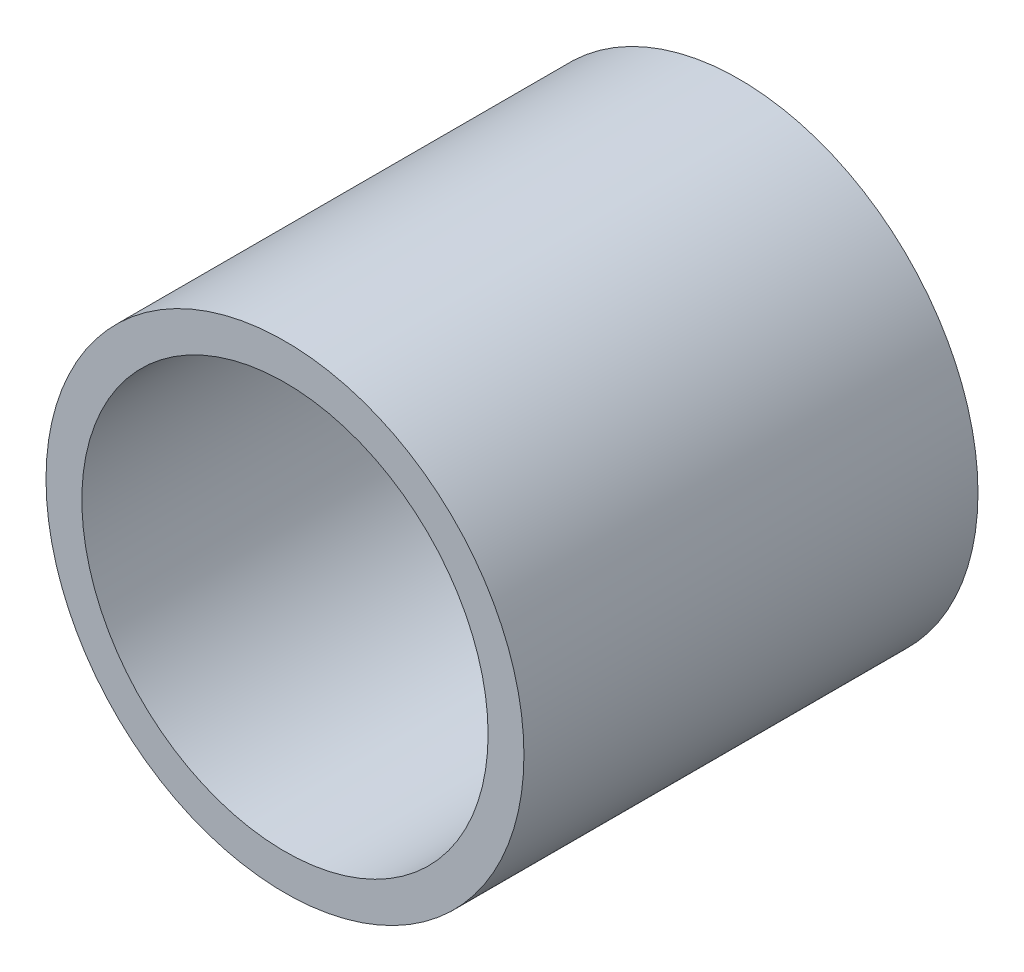
from build123d import *

# Parameters (mm, degrees)
SKETCH1_R           = 20
SKETCH1_R_2         = 17
BOSS_EXTRUDE1_DEPTH = 38


with BuildPart() as part:
    # Sketch1 → Boss-Extrude1 (new body)
    with BuildSketch(Plane.XY):
        Circle(SKETCH1_R)
        Circle(SKETCH1_R_2, mode=Mode.SUBTRACT)
    extrude(amount=BOSS_EXTRUDE1_DEPTH)


solid = part.part
